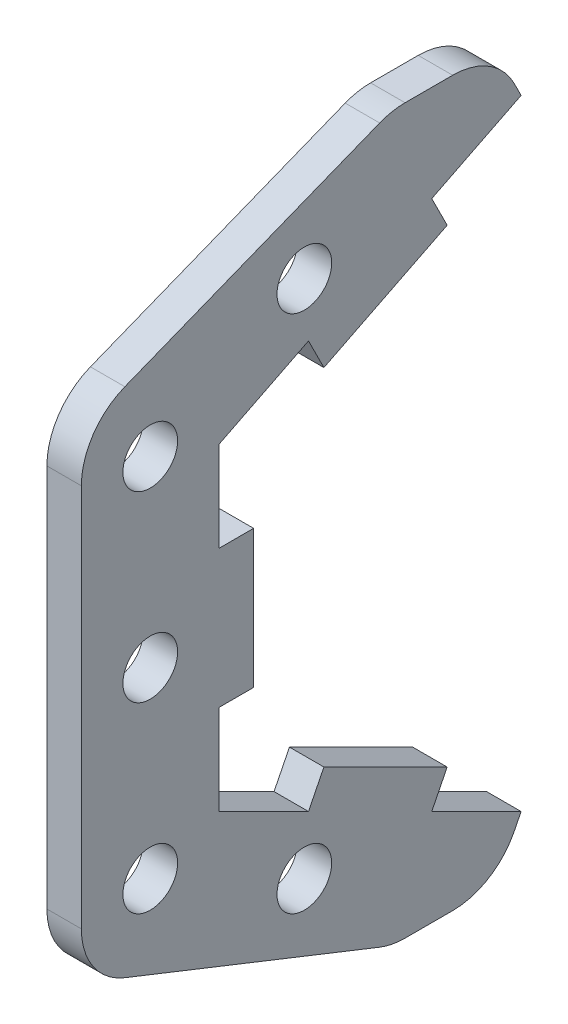
from build123d import *

# Parameters (mm, degrees)
SKETCH1_R                   = 7.9375
SKETCH1_R_2                 = 11.1125
BOSS_EXTRUDE1_DEPTH         = 12.7
F_8_CLEARANCE_HOLE1_D       = 4.4958
SKETCH5_R                   = 18.415
CUT_EXTRUDE1_DEPTH          = 13.7
SKETCH7_R                   = 9.525
CUT_EXTRUDE2_DEPTH          = 13.7
CUT_EXTRUDE3_DEPTH          = 13.7
BOSS_EXTRUDE2_DEPTH         = 12.7
CUT_EXTRUDE4_DEPTH          = 13.7
SKETCH11_W                  = 12.7
SKETCH11_H                  = 178.054
CUT_EXTRUDE5_DEPTH          = 3.175
BOSS_EXTRUDE3_DEPTH         = 6.35
CUT_EXTRUDE6_DEPTH          = 13.7
F_3_8_CLEARANCE_HOLE1_D     = 10.0838
F_3_8_CLEARANCE_HOLE1_DEPTH = 12.7
F_3_8_CLEARANCE_HOLE1_TIP   = 3.029479155
FILLET1_R                   = 12.7
SKETCH16_W                  = 6.35
SKETCH16_H                  = 25.4
BOSS_EXTRUDE4_DEPTH         = 6.35


with BuildPart() as part:
    # Sketch1 → Boss-Extrude1 (new body)
    with BuildSketch(Plane(origin=(0, 0, 0), x_dir=(0, 0, -1), z_dir=(1, 0, 0))):
        with BuildLine():
            Line((93.345, 0), (55.245, 50.8))
            Line((55.245, 50.8), (-160.655, 50.8))
            ThreePointArc((-160.655, 50.8), (-211.455, 0), (-160.655, -50.8))
            Line((-160.655, -50.8), (55.245, -50.8))
            Line((55.245, -50.8), (93.345, 0))
        make_face()
        with Locations((-88.9, 0)):
            Circle(SKETCH1_R, mode=Mode.SUBTRACT)
        with Locations((-38.1, 0)):
            Circle(SKETCH1_R, mode=Mode.SUBTRACT)
        with Locations((-160.655, 0)):
            Circle(SKETCH1_R_2, mode=Mode.SUBTRACT)
        Circle(SKETCH1_R, mode=Mode.SUBTRACT)
    extrude(amount=BOSS_EXTRUDE1_DEPTH)

    # #8 Clearance Hole1 (through all)
    with Locations(Plane.ZY):
        with Locations((-17.691104559, 17.691104559), (17.691104559, 17.691104559), (17.691104559, -17.691104559), (-17.691104559, -17.691104559)):
            Hole(F_8_CLEARANCE_HOLE1_D / 2)

    # Sketch5 → Cut-Extrude1 (cut, through all)
    with BuildSketch(Plane.ZY):
        Circle(SKETCH5_R)
    extrude(amount=-CUT_EXTRUDE1_DEPTH, mode=Mode.SUBTRACT)

    # Sketch7 → Cut-Extrude2 (cut, through all)
    with BuildSketch(Plane.ZY):
        with Locations((-55.245, 0)):
            Circle(SKETCH7_R)
    extrude(amount=-CUT_EXTRUDE2_DEPTH, mode=Mode.SUBTRACT)

    # Sketch8 → Cut-Extrude3 (cut, through all)
    with BuildSketch(Plane(origin=(12.7, 0, 0), x_dir=(0, 0, -1), z_dir=(1, 0, 0))):
        Polygon((-160.655, 50.8), (-211.455, 25.4), (-211.455, -25.4), (-160.655, -50.8), (-233.239745749, -50.8), (-233.239745749, 50.8), align=None)
    extrude(amount=-CUT_EXTRUDE3_DEPTH, mode=Mode.SUBTRACT)

    # Sketch9 → Boss-Extrude2 (add)
    with BuildSketch(Plane(origin=(12.7, 0, 0), x_dir=(0, 0, -1), z_dir=(1, 0, 0))):
        Polygon((-160.655, 50.8), (-211.455, 25.4), (-211.455, 0), (-211.455, -25.4), (-160.655, -50.8), (-160.655, -40.64), (-202.749323348, 0), (-160.655, 40.64), align=None)
    extrude(amount=-BOSS_EXTRUDE2_DEPTH)

    # Sketch10 → Cut-Extrude4 (cut, through all)
    with BuildSketch(Plane.ZY):
        Polygon((-79.0575, -19.05), (-79.0575, 19.05), (-93.345, 0), align=None)
    extrude(amount=-CUT_EXTRUDE4_DEPTH, mode=Mode.SUBTRACT)

    # Sketch11 → Cut-Extrude5 (cut)
    with BuildSketch(Plane(origin=(0, 50.8, 0), x_dir=(1, 0, 0), z_dir=(0, 1, 0))):
        with Locations((6.35, -52.705)):
            Rectangle(SKETCH11_W, SKETCH11_H)
    cut_extrude5 = extrude(amount=-CUT_EXTRUDE5_DEPTH, mode=Mode.SUBTRACT)

    # Mirror1: Cut-Extrude5 across plane
    add(cut_extrude5.mirror(Plane.ZX), mode=Mode.SUBTRACT)

    # Sketch13 → Cut-Extrude6 (cut, through all)
    with BuildSketch(Plane(origin=(12.7, 0, 0), x_dir=(0, 0, -1), z_dir=(1, 0, 0))):
        Polygon((-161.254612663, -53.34), (-139.192, -53.34), (-139.192, -50.165), (33.782, -50.165), (33.782, -53.34), (56.515, -53.34), (81.5975, -19.896666667), (81.5975, 19.896666667), (56.515, 53.34), (33.782, 53.34), (33.782, 50.165), (-139.192, 50.165), (-139.192, 53.34), (-161.254612663, 53.34), (-213.995, 26.969806331), (-213.995, -26.969806331), align=None)
    extrude(amount=-CUT_EXTRUDE6_DEPTH, mode=Mode.SUBTRACT)


with BuildPart() as body_2:
    # Sketch12 → Boss-Extrude3 (new body)
    with BuildSketch(Plane(origin=(12.7, 0, 0), x_dir=(0, 0, -1), z_dir=(1, 0, 0))):
        with BuildLine():
            ThreePointArc((-211.89681554, -56.397839854), (-236.855, 0), (-211.89681554, 56.397839854))
            Line((-211.89681554, 56.397839854), (-243.205, 43.989212666))
            Line((-243.205, 43.989212666), (-243.205, -43.989212666))
            Line((-243.205, -43.989212666), (-211.89681554, -56.397839854))
        make_face()
        with BuildLine():
            Line((-217.805, 29.324515829), (-162.154031657, 57.15))
            Line((-162.154031657, 57.15), (-166.916531657, 66.675))
            Line((-166.916531657, 66.675), (-185.966531657, 66.675))
            Line((-185.966531657, 66.675), (-211.89681554, 56.397839854))
            ThreePointArc((-211.89681554, 56.397839854), (-236.855, 0), (-211.89681554, -56.397839854))
            Line((-211.89681554, -56.397839854), (-185.966531657, -66.675))
            Line((-185.966531657, -66.675), (-166.916531657, -66.675))
            Line((-166.916531657, -66.675), (-162.154031657, -57.15))
            Line((-162.154031657, -57.15), (-217.805, -29.324515829))
            Line((-217.805, -29.324515829), (-217.805, 29.324515829))
        make_face()
    extrude(amount=-BOSS_EXTRUDE3_DEPTH)

    # 3/8 Clearance Hole1
    with Locations(Plane(origin=(12.7, 0, 0), x_dir=(0, 0, -1), z_dir=(1, 0, 0))):
        with Locations((-230.505, 0), (-230.505, 33.690140829), (-202.106936686, 47.889172486), (-230.505, -33.690140829), (-202.106936686, -47.889172486)):
            Hole(F_3_8_CLEARANCE_HOLE1_D / 2, depth=F_3_8_CLEARANCE_HOLE1_DEPTH)
            with Locations((0, 0, -(F_3_8_CLEARANCE_HOLE1_DEPTH + F_3_8_CLEARANCE_HOLE1_TIP / 2))):  # 118° drill point
                Cone(0, F_3_8_CLEARANCE_HOLE1_D / 2, F_3_8_CLEARANCE_HOLE1_TIP, mode=Mode.SUBTRACT)

    # Fillet1
    fillet1_edges = [body_2.edges().sort_by_distance(p)[0] for p in [
        (9.525, -43.989212666, 243.205),
        (9.525, 43.989212666, 243.205),
        (9.525, 66.675, 185.966531657),
        (9.525, 66.675, 166.916531657),
        (9.525, -66.675, 166.916531657),
        (9.525, -66.675, 185.966531657),
    ]]
    fillet(fillet1_edges, radius=FILLET1_R)

    # Sketch16 → Boss-Extrude4 (add)
    with BuildSketch(Plane(origin=(12.7, 0, 0), x_dir=(0, 0, -1), z_dir=(1, 0, 0))):
        with Locations((-214.63, 0)):
            Rectangle(SKETCH16_W, SKETCH16_H)
        Polygon((-178.620290503, -48.916870577), (-175.780484171, -43.237257914), (-198.498934823, -31.878032589), (-201.338741154, -37.557645251), align=None)
        Polygon((-201.338741154, 37.557645251), (-198.498934823, 31.878032589), (-175.780484171, 43.237257914), (-178.620290503, 48.916870577), align=None)
    extrude(amount=-BOSS_EXTRUDE4_DEPTH)


solid = body_2.part
